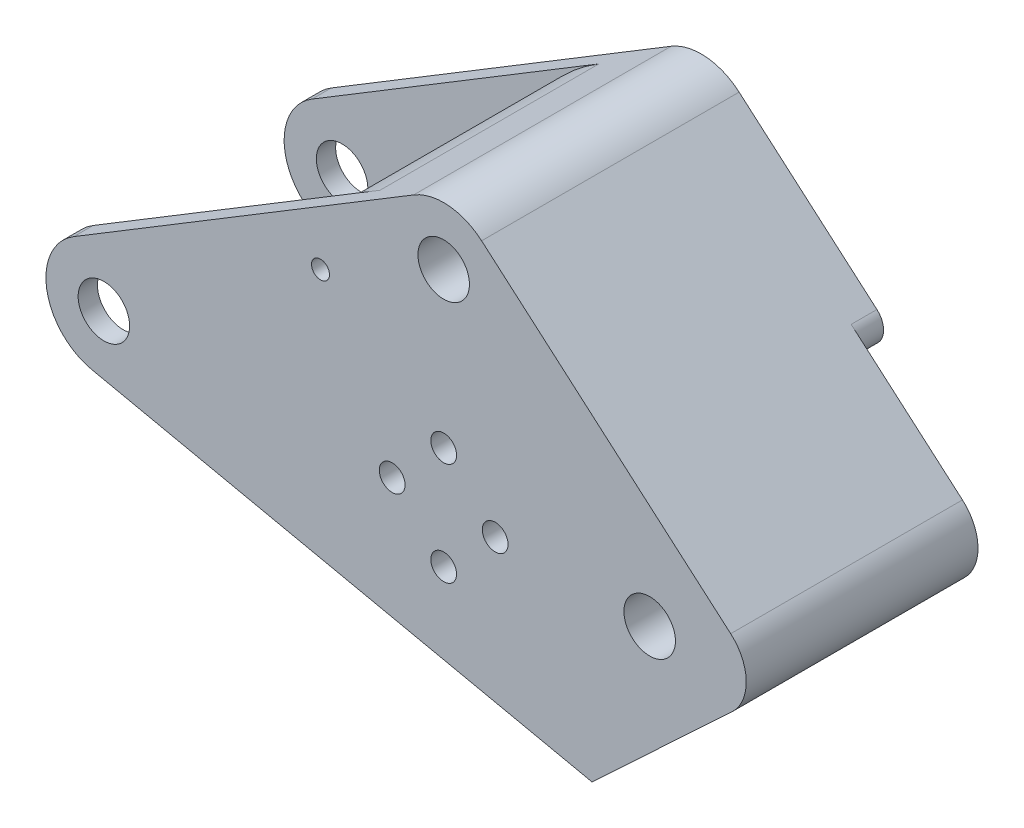
from build123d import *

# Parameters (mm, degrees)
SKETCH1_R               = 4
SKETCH1_R_2             = 2
BOSS_EXTRUDE1_DEPTH     = 20
CUT_EXTRUDE1_DEPTH      = 17
CUT_EXTRUDE1_DEPTH_BACK = 17
SKETCH3_R               = 4
CUT_EXTRUDE2_DEPTH      = 37
SKETCH4_R               = 1.395
CUT_EXTRUDE3_DEPTH      = 41
CUT_EXTRUDE4_DEPTH      = 4
FILLET1_R               = 3


with BuildPart() as part:
    # Sketch1 → Boss-Extrude1 (new body, symmetric)
    with BuildSketch(Plane.XY):
        with BuildLine():
            Line((-4.665710042, 7.69617761), (48.118899649, 39.69617761))
            ThreePointArc((48.118899649, 39.69617761), (53.543313423, 40.967963461), (58.676968473, 38.802948477))
            Line((58.676968473, 38.802948477), (97.36755541, 5.291182149))
            ThreePointArc((97.36755541, 5.291182149), (99.783371388, 0.131661326), (97.563318746, -5.115069869))
            Line((97.563318746, -5.115069869), (75.824988549, -25.423913737))
            Line((75.824988549, -25.423913737), (-1.882663558, -8.800885065))
            ThreePointArc((-1.882663558, -8.800885065), (-8.874602438, -1.497141134), (-4.665710042, 7.69617761))
        make_face()
        Circle(SKETCH1_R, mode=Mode.SUBTRACT)
        with Locations((84.784609691, 0)):
            Circle(SKETCH1_R, mode=Mode.SUBTRACT)
        with Locations((60.784609691, 0)):
            Circle(SKETCH1_R_2, mode=Mode.SUBTRACT)
        with Locations((52.784609691, -8)):
            Circle(SKETCH1_R_2, mode=Mode.SUBTRACT)
        with Locations((44.784609691, 0)):
            Circle(SKETCH1_R_2, mode=Mode.SUBTRACT)
        with Locations((52.784609691, 8)):
            Circle(SKETCH1_R_2, mode=Mode.SUBTRACT)
        with Locations((52.784609691, 32)):
            Circle(SKETCH1_R, mode=Mode.SUBTRACT)
    extrude(amount=BOSS_EXTRUDE1_DEPTH, both=True)

    # Sketch2 → Cut-Extrude1 (cut, two sides)
    with BuildSketch(Plane.XY) as cut_extrude1_sk:
        with BuildLine():
            Line((-4.665710042, 7.69617761), (39.891888688, 34.708656583))
            ThreePointArc((39.891888688, 34.708656583), (26.010438267, 4.38794834), (49.070722017, -19.700707237))
            Line((49.070722017, -19.700707237), (-1.882663558, -8.800885065))
            ThreePointArc((-1.882663558, -8.800885065), (-8.874602438, -1.497141134), (-4.665710042, 7.69617761))
        make_face()
    extrude(amount=CUT_EXTRUDE1_DEPTH, mode=Mode.SUBTRACT)
    extrude(cut_extrude1_sk.sketch, amount=-CUT_EXTRUDE1_DEPTH_BACK, mode=Mode.SUBTRACT)

    # Sketch3 → Cut-Extrude2 (cut)
    with BuildSketch(Plane(origin=(0, 0, -20), x_dir=(-1, 0, 0), z_dir=(0, 0, -1))):
        with Locations((-52.784609691, 8)):
            Circle(SKETCH3_R)
        with Locations((-60.784609691, 0)):
            Circle(SKETCH3_R)
        with Locations((-52.784609691, -8)):
            Circle(SKETCH3_R)
        with Locations((-44.784609691, 0)):
            Circle(SKETCH3_R)
    extrude(amount=-CUT_EXTRUDE2_DEPTH, mode=Mode.SUBTRACT)

    # Sketch4 → Cut-Extrude3 (cut, through all)
    with BuildSketch(Plane.XY.offset(20)):
        with Locations((33.650538517, 22.427469232)):
            Circle(SKETCH4_R)
    extrude(amount=-CUT_EXTRUDE3_DEPTH, mode=Mode.SUBTRACT)

    # Sketch5 → Cut-Extrude4 (cut)
    with BuildSketch(Plane(origin=(0, 0, -20), x_dir=(-1, 0, 0), z_dir=(0, 0, -1))):
        with BuildLine():
            Line((-97.36755541, 5.291182149), (-84.784609691, 16.189872762))
            ThreePointArc((-84.784609691, 16.189872762), (-68.601779215, -0.477470257), (-85.739134824, -16.161709743))
            Line((-85.739134824, -16.161709743), (-97.563318746, -5.115069869))
            ThreePointArc((-97.563318746, -5.115069869), (-99.783371388, 0.131661326), (-97.36755541, 5.291182149))
        make_face()
    extrude(amount=-CUT_EXTRUDE4_DEPTH, mode=Mode.SUBTRACT)

    # Fillet1
    fillet1_edges = [part.edges().sort_by_distance(p)[0] for p in [
        (84.784609691, 16.189872762, -18),
        (85.739134824, -16.161709743, -18),
    ]]
    fillet(fillet1_edges, radius=FILLET1_R)


solid = part.part
